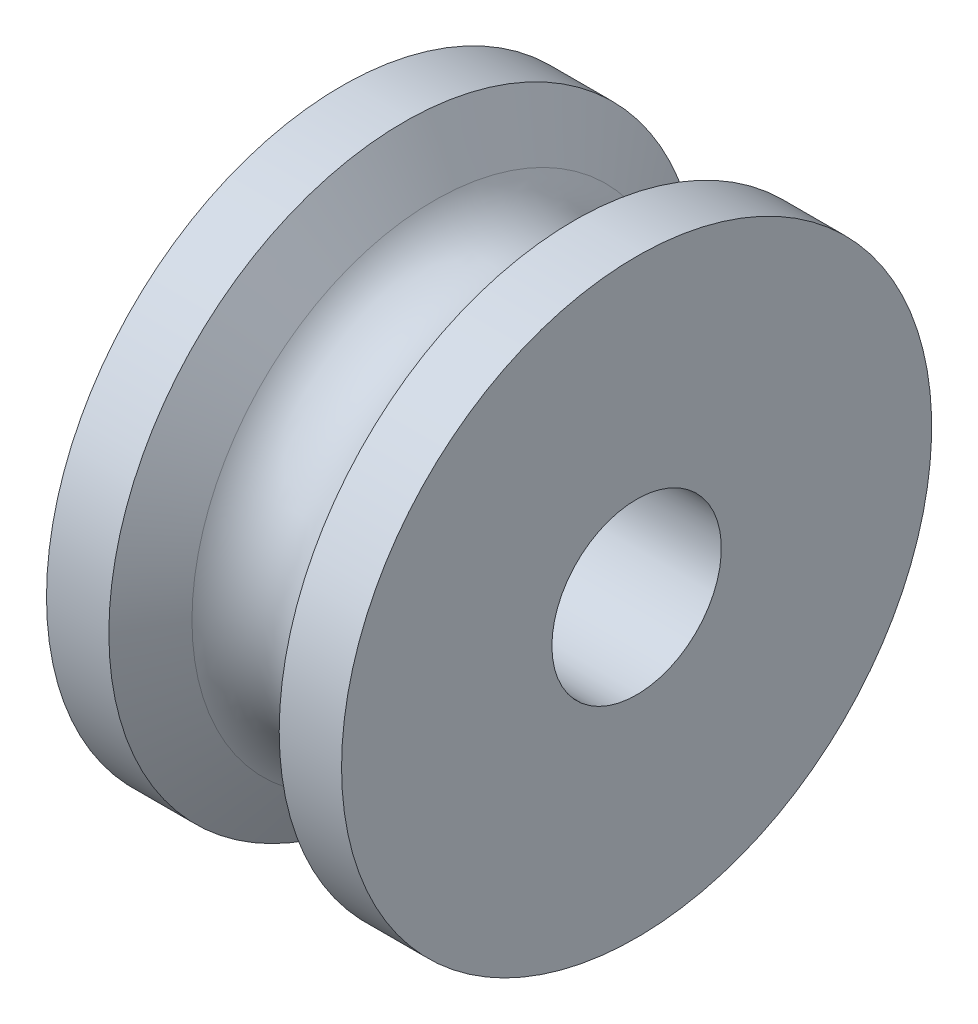
from build123d import *


with BuildPart() as part:
    # Sketch1 → Revolve1 (revolve)
    with BuildSketch(Plane.XY):
        with BuildLine():
            Line((0, 2.5527), (8.89, 2.5527))
            Line((8.89, 2.5527), (8.89, 8.89))
            Line((8.89, 8.89), (7.011321947, 8.89))
            Line((7.011321947, 8.89), (6.094778394, 7.3025))
            ThreePointArc((6.094778394, 7.3025), (4.445, 6.35), (2.795221606, 7.3025))
            Line((2.795221606, 7.3025), (1.878678053, 8.89))
            Line((1.878678053, 8.89), (0, 8.89))
            Line((0, 8.89), (0, 2.5527))
        make_face()
    revolve(axis=Axis((0, 0, 0), (1, 0, 0)))


solid = part.part
